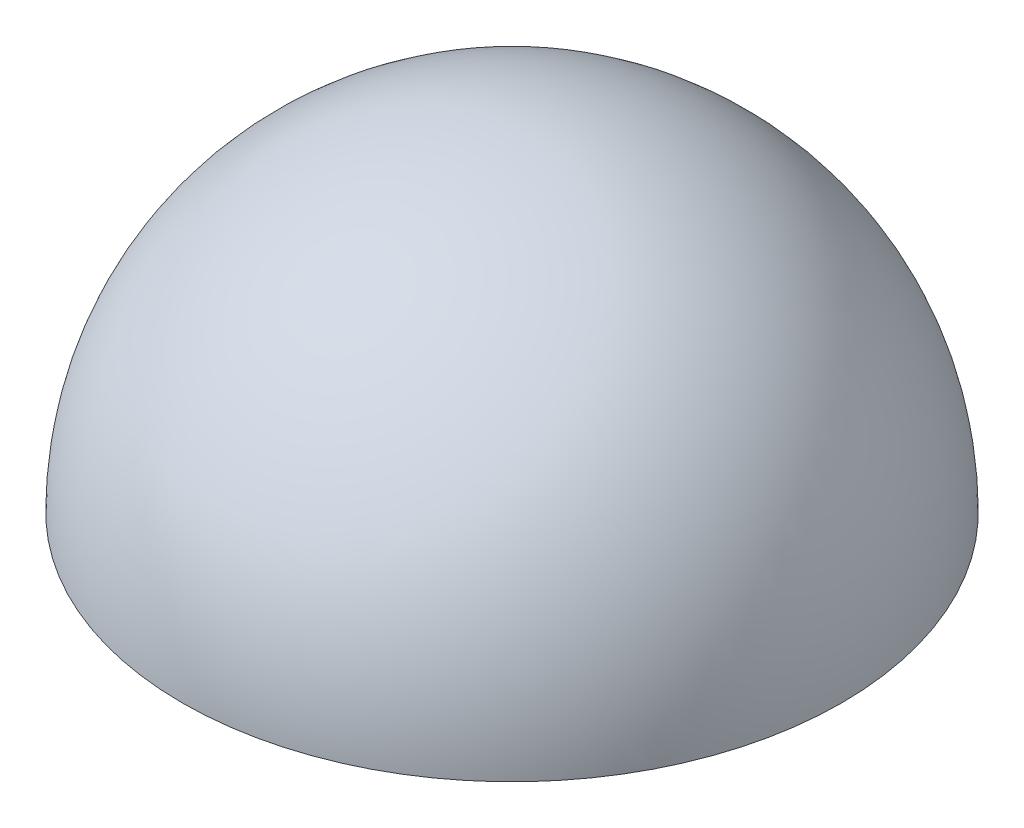
from build123d import *


with BuildPart() as part:
    # Sketch1 → Revolve2 (revolve)
    with BuildSketch(Plane.XY):
        with BuildLine():
            Line((-12.7, 0), (-13.2, 0))
            ThreePointArc((-13.2, 0), (-9.333809512, 9.333809512), (0, 13.2))
            Line((0, 13.2), (0, 12.7))
            ThreePointArc((0, 12.7), (-8.980256121, 8.980256121), (-12.7, 0))
        make_face()
    revolve(axis=Axis((0, 0, 0), (0, 1, 0)))


solid = part.part
